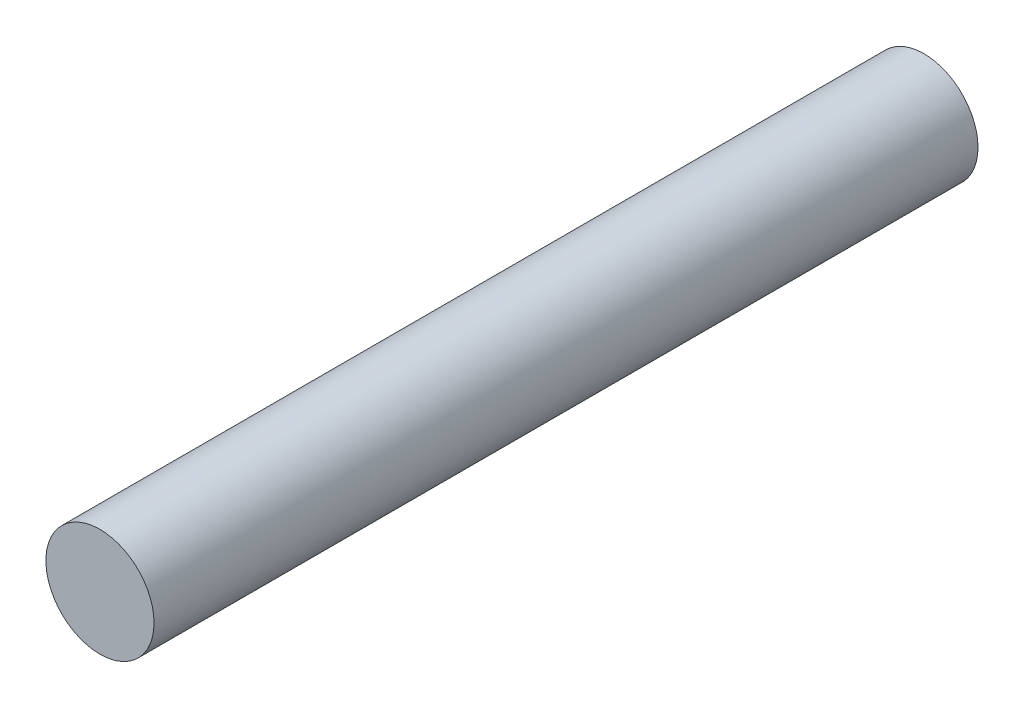
from build123d import *

# Parameters (mm, degrees)
SKETCH1_R           = 2.5
BOSS_EXTRUDE1_DEPTH = 19.05


with BuildPart() as part:
    # Sketch1 → Boss-Extrude1 (new body, symmetric)
    with BuildSketch(Plane.XY):
        Circle(SKETCH1_R)
    extrude(amount=BOSS_EXTRUDE1_DEPTH, both=True)


solid = part.part
